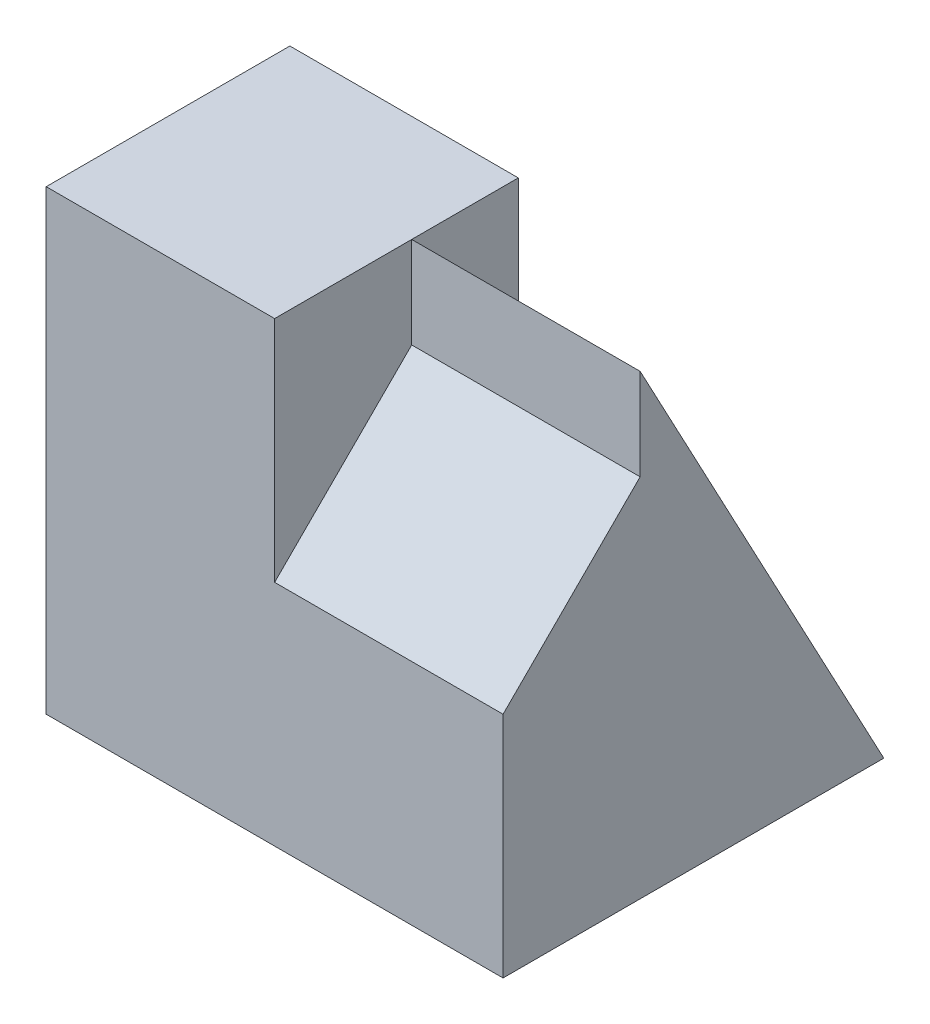
from build123d import *

# Parameters (mm, degrees)
BOSS_EXTRUDE1_DEPTH = 3
SKETCH2_W           = 3.2
SKETCH2_H           = 6
BOSS_EXTRUDE2_DEPTH = 3
BOSS_EXTRUDE3_DEPTH = 3


with BuildPart() as part:
    # Sketch1 → Boss-Extrude1 (new body)
    with BuildSketch(Plane(origin=(0, 0, 0), x_dir=(0, 0, -1), z_dir=(1, 0, 0))):
        Polygon((0, 0), (0, 3), (1.8, 4.8), (1.8, 6), (5, 0), align=None)
    extrude(amount=BOSS_EXTRUDE1_DEPTH)

    # Sketch2 → Boss-Extrude2 (add)
    with BuildSketch(Plane.ZY):
        with Locations((-1.6, 3)):
            Rectangle(SKETCH2_W, SKETCH2_H)
    extrude(amount=BOSS_EXTRUDE2_DEPTH)

    # Sketch3 → Boss-Extrude3 (add)
    with BuildSketch(Plane.ZY):
        Polygon((-5, 0), (-3.2, 0), (-3.2, 3.375), align=None)
    extrude(amount=BOSS_EXTRUDE3_DEPTH)


solid = part.part
